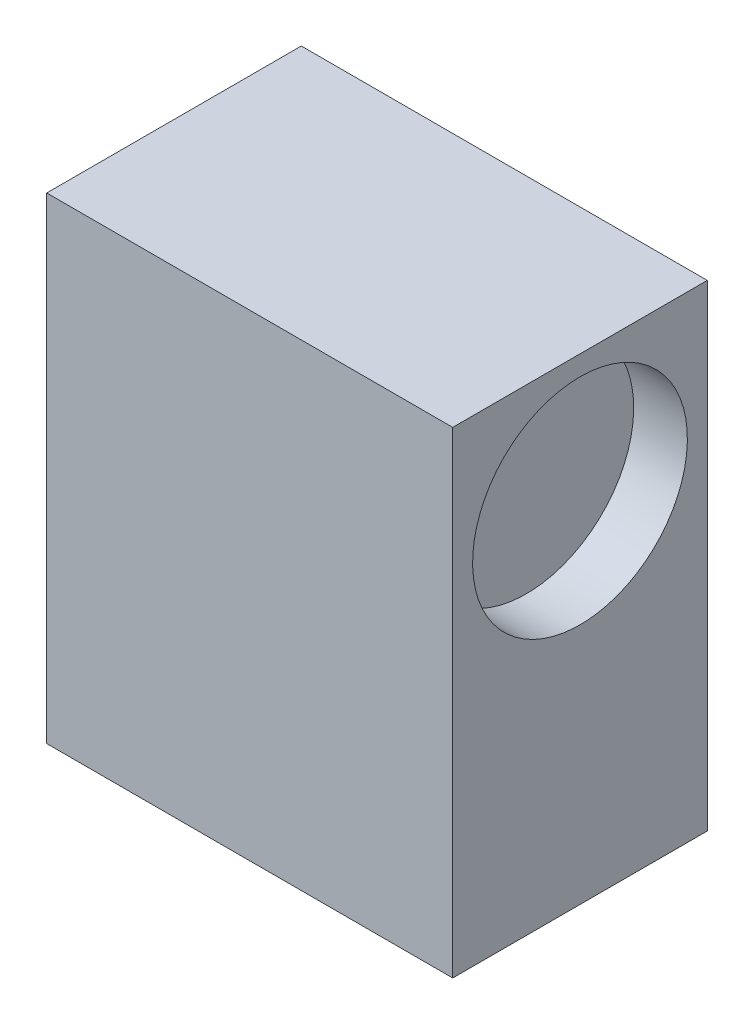
from build123d import *

# Parameters (mm, degrees)
SKETCH1_W           = 37.8
SKETCH1_H           = 44.4
BOSS_EXTRUDE1_DEPTH = 23.7
SKETCH2_R           = 10
CUT_EXTRUDE1_DEPTH  = 5


with BuildPart() as part:
    # Sketch1 → Boss-Extrude1 (new body)
    with BuildSketch(Plane.XY):
        with Locations((15.249090909, -6.911818182)):
            Rectangle(SKETCH1_W, SKETCH1_H)
    extrude(amount=BOSS_EXTRUDE1_DEPTH)

    # Sketch2 → Cut-Extrude1 (cut)
    with BuildSketch(Plane(origin=(34.149090909, 0, 0), x_dir=(0, 0, -1), z_dir=(1, 0, 0))):
        with Locations((-11.85, 3.438181818)):
            Circle(SKETCH2_R)
    cut_extrude1 = extrude(amount=-CUT_EXTRUDE1_DEPTH, mode=Mode.SUBTRACT)

    # Mirror1: Cut-Extrude1 across plane
    add(cut_extrude1.mirror(Plane(origin=(15.249090909, 0, 0), x_dir=(0, 0, 1), z_dir=(1, 0, 0))), mode=Mode.SUBTRACT)


solid = part.part
